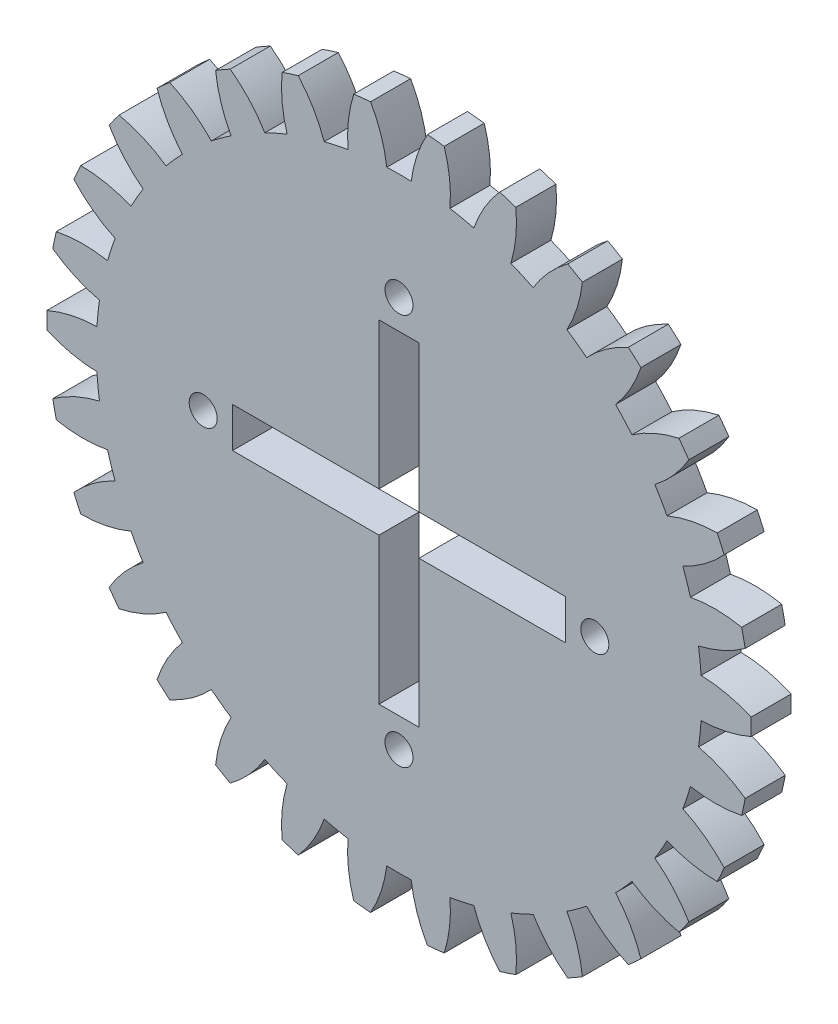
from build123d import *

# Parameters (mm, degrees)
EXTRUDE_1_DEPTH     = 5
CUT_EXTRUDE_2_DEPTH = 10
SKETCH_4_R          = 1.75
CUT_EXTRUDE_3_DEPTH = 10


with BuildPart() as part:
    # 草图1 → 凸台-拉伸1 (new body)
    with BuildSketch(Plane.XY):
        with BuildLine():
            ThreePointArc((-43.98730465, -1.056896208), (-40.927651292, -2.051995365), (-37.733051967, -2.434403732))
            ThreePointArc((-37.733051967, -2.434403732), (-37.604364647, -3.952377989), (-37.414635246, -5.463936465))
            ThreePointArc((-37.414635246, -5.463936465), (-40.459917741, -6.502182838), (-43.245817584, -8.111674394))
            ThreePointArc((-43.245817584, -8.111674394), (-43.038494432, -9.148114396), (-42.806335429, -10.179275375))
            ThreePointArc((-42.806335429, -10.179275375), (-39.606650089, -10.516491524), (-36.402353254, -10.226348803))
            ThreePointArc((-36.402353254, -10.226348803), (-35.960873466, -11.684396083), (-35.461019429, -13.123476419))
            ThreePointArc((-35.461019429, -13.123476419), (-38.223891636, -14.772184451), (-40.614280773, -16.925725901))
            ThreePointArc((-40.614280773, -16.925725901), (-40.196000136, -17.896412295), (-39.754523941, -18.856771362))
            ThreePointArc((-39.754523941, -18.856771362), (-36.554648223, -18.52136654), (-33.480697026, -17.571353361))
            ThreePointArc((-33.480697026, -17.571353361), (-32.745719555, -18.90575), (-31.957586902, -20.20945748))
            ThreePointArc((-31.957586902, -20.20945748), (-34.317298048, -22.396570718), (-36.207705003, -25.000041968))
            ThreePointArc((-36.207705003, -25.000041968), (-35.596747752, -25.862551101), (-34.965248994, -26.710135956))
            ThreePointArc((-34.965248994, -26.710135956), (-31.905032822, -25.716768963), (-29.095773679, -24.14840546))
            ThreePointArc((-29.095773679, -24.14840546), (-28.099420569, -25.300831922), (-27.057454478, -26.412188274))
            ThreePointArc((-27.057454478, -26.412188274), (-28.910873863, -29.042119374), (-30.218678781, -31.981736237))
            ThreePointArc((-30.218678781, -31.981736237), (-29.44174668, -32.698372321), (-28.647824884, -33.396139438))
            ThreePointArc((-28.647824884, -33.396139438), (-25.861014388, -31.788225179), (-23.439225406, -29.670056364))
            ThreePointArc((-23.439225406, -29.670056364), (-22.225042067, -30.590146083), (-20.974781458, -31.4605797))
            ThreePointArc((-20.974781458, -31.4605797), (-22.24090576, -34.418388053), (-22.908951291, -37.565675167))
            ThreePointArc((-22.908951291, -37.565675167), (-22, -38.105117767), (-21.07835336, -38.622571375))
            ThreePointArc((-21.07835336, -38.622571375), (-18.686745531, -36.470383418), (-16.758270509, -33.894983431))
            ThreePointArc((-16.758270509, -33.894983431), (-15.37932258, -34.542524072), (-13.97540984, -35.133992828))
            ThreePointArc((-13.97540984, -35.133992828), (-14.598903352, -38.290408018), (-14.5979927, -41.507813832))
            ThreePointArc((-14.5979927, -41.507813832), (-13.596747752, -41.846486717), (-12.587656648, -42.161011612))
            ThreePointArc((-12.587656648, -42.161011612), (-10.695776226, -39.558610898), (-9.344898775, -36.638537077))
            ThreePointArc((-9.344898775, -36.638537077), (-7.861452897, -36.985228005), (-6.36524575, -37.271881879))
            ThreePointArc((-6.36524575, -37.271881879), (-6.318858814, -40.488953413), (-5.649031779, -43.635861857))
            ThreePointArc((-5.649031779, -43.635861857), (-4.599252384, -43.758963396), (-3.546818938, -43.85681333))
            ThreePointArc((-3.546818938, -43.85681333), (-2.237350175, -40.917937258), (-1.523110123, -37.780810841))
            ThreePointArc((-1.523110123, -37.780810841), (0, -37.8115), (1.523110123, -37.780810841))
            ThreePointArc((1.523110123, -37.780810841), (2.237350175, -40.917937258), (3.546818938, -43.85681333))
            ThreePointArc((3.546818938, -43.85681333), (4.599252384, -43.758963396), (5.649031779, -43.635861857))
            ThreePointArc((5.649031779, -43.635861857), (6.318858814, -40.488953413), (6.36524575, -37.271881879))
            ThreePointArc((6.36524575, -37.271881879), (7.861452897, -36.985228005), (9.344898775, -36.638537077))
            ThreePointArc((9.344898775, -36.638537077), (10.695776226, -39.558610898), (12.587656648, -42.161011612))
            ThreePointArc((12.587656648, -42.161011612), (13.596747752, -41.846486717), (14.5979927, -41.507813832))
            ThreePointArc((14.5979927, -41.507813832), (14.598903352, -38.290408018), (13.97540984, -35.133992828))
            ThreePointArc((13.97540984, -35.133992828), (15.37932258, -34.542524072), (16.758270509, -33.894983431))
            ThreePointArc((16.758270509, -33.894983431), (18.686745531, -36.470383418), (21.07835336, -38.622571375))
            ThreePointArc((21.07835336, -38.622571375), (22, -38.105117767), (22.908951291, -37.565675167))
            ThreePointArc((22.908951291, -37.565675167), (22.24090576, -34.418388053), (20.974781458, -31.4605797))
            ThreePointArc((20.974781458, -31.4605797), (22.225042067, -30.590146083), (23.439225406, -29.670056364))
            ThreePointArc((23.439225406, -29.670056364), (25.861014388, -31.788225179), (28.647824884, -33.396139438))
            ThreePointArc((28.647824884, -33.396139438), (29.44174668, -32.698372321), (30.218678781, -31.981736237))
            ThreePointArc((30.218678781, -31.981736237), (28.910873863, -29.042119374), (27.057454478, -26.412188274))
            ThreePointArc((27.057454478, -26.412188274), (28.099420569, -25.300831922), (29.095773679, -24.14840546))
            ThreePointArc((29.095773679, -24.14840546), (31.905032822, -25.716768963), (34.965248994, -26.710135956))
            ThreePointArc((34.965248994, -26.710135956), (35.596747752, -25.862551101), (36.207705003, -25.000041968))
            ThreePointArc((36.207705003, -25.000041968), (34.317298048, -22.396570718), (31.957586902, -20.20945748))
            ThreePointArc((31.957586902, -20.20945748), (32.745719555, -18.90575), (33.480697026, -17.571353361))
            ThreePointArc((33.480697026, -17.571353361), (36.554648223, -18.52136654), (39.754523941, -18.856771362))
            ThreePointArc((39.754523941, -18.856771362), (40.196000136, -17.896412295), (40.614280773, -16.925725901))
            ThreePointArc((40.614280773, -16.925725901), (38.223891636, -14.772184451), (35.461019429, -13.123476419))
            ThreePointArc((35.461019429, -13.123476419), (35.960873466, -11.684396083), (36.402353254, -10.226348803))
            ThreePointArc((36.402353254, -10.226348803), (39.606650089, -10.516491524), (42.806335429, -10.179275375))
            ThreePointArc((42.806335429, -10.179275375), (43.038494432, -9.148114396), (43.245817584, -8.111674394))
            ThreePointArc((43.245817584, -8.111674394), (40.459917741, -6.502182838), (37.414635246, -5.463936465))
            ThreePointArc((37.414635246, -5.463936465), (37.604364647, -3.952377989), (37.733051967, -2.434403732))
            ThreePointArc((37.733051967, -2.434403732), (40.927651292, -2.051995365), (43.98730465, -1.056896208))
            ThreePointArc((43.98730465, -1.056896208), (44, 0), (43.98730465, 1.056896208))
            ThreePointArc((43.98730465, 1.056896208), (40.927651292, 2.051995365), (37.733051967, 2.434403732))
            ThreePointArc((37.733051967, 2.434403732), (37.604364647, 3.952377989), (37.414635246, 5.463936465))
            ThreePointArc((37.414635246, 5.463936465), (40.459917741, 6.502182838), (43.245817584, 8.111674394))
            ThreePointArc((43.245817584, 8.111674394), (43.038494432, 9.148114396), (42.806335429, 10.179275375))
            ThreePointArc((42.806335429, 10.179275375), (39.606650089, 10.516491524), (36.402353254, 10.226348803))
            ThreePointArc((36.402353254, 10.226348803), (35.960873466, 11.684396083), (35.461019429, 13.123476419))
            ThreePointArc((35.461019429, 13.123476419), (38.223891636, 14.772184451), (40.614280773, 16.925725901))
            ThreePointArc((40.614280773, 16.925725901), (40.196000136, 17.896412295), (39.754523941, 18.856771362))
            ThreePointArc((39.754523941, 18.856771362), (36.554648223, 18.52136654), (33.480697026, 17.571353361))
            ThreePointArc((33.480697026, 17.571353361), (32.745719555, 18.90575), (31.957586902, 20.20945748))
            ThreePointArc((31.957586902, 20.20945748), (34.317298048, 22.396570718), (36.207705003, 25.000041968))
            ThreePointArc((36.207705003, 25.000041968), (35.596747752, 25.862551101), (34.965248994, 26.710135956))
            ThreePointArc((34.965248994, 26.710135956), (31.905032822, 25.716768963), (29.095773679, 24.14840546))
            ThreePointArc((29.095773679, 24.14840546), (28.099420569, 25.300831922), (27.057454478, 26.412188274))
            ThreePointArc((27.057454478, 26.412188274), (28.910873863, 29.042119374), (30.218678781, 31.981736237))
            ThreePointArc((30.218678781, 31.981736237), (29.44174668, 32.698372321), (28.647824884, 33.396139438))
            ThreePointArc((28.647824884, 33.396139438), (25.861014388, 31.788225179), (23.439225406, 29.670056364))
            ThreePointArc((23.439225406, 29.670056364), (22.225042067, 30.590146083), (20.974781458, 31.4605797))
            ThreePointArc((20.974781458, 31.4605797), (22.24090576, 34.418388053), (22.908951291, 37.565675167))
            ThreePointArc((22.908951291, 37.565675167), (22, 38.105117767), (21.07835336, 38.622571375))
            ThreePointArc((21.07835336, 38.622571375), (18.686745531, 36.470383418), (16.758270509, 33.894983431))
            ThreePointArc((16.758270509, 33.894983431), (15.37932258, 34.542524072), (13.97540984, 35.133992828))
            ThreePointArc((13.97540984, 35.133992828), (14.598903352, 38.290408018), (14.5979927, 41.507813832))
            ThreePointArc((14.5979927, 41.507813832), (13.596747752, 41.846486717), (12.587656648, 42.161011612))
            ThreePointArc((12.587656648, 42.161011612), (10.695776226, 39.558610898), (9.344898775, 36.638537077))
            ThreePointArc((9.344898775, 36.638537077), (7.861452897, 36.985228005), (6.36524575, 37.271881879))
            ThreePointArc((6.36524575, 37.271881879), (6.318858814, 40.488953413), (5.649031779, 43.635861857))
            ThreePointArc((5.649031779, 43.635861857), (4.599252384, 43.758963396), (3.546818938, 43.85681333))
            ThreePointArc((3.546818938, 43.85681333), (2.237350175, 40.917937258), (1.523110123, 37.780810841))
            ThreePointArc((1.523110123, 37.780810841), (0, 37.8115), (-1.523110123, 37.780810841))
            ThreePointArc((-1.523110123, 37.780810841), (-2.237350175, 40.917937258), (-3.546818938, 43.85681333))
            ThreePointArc((-3.546818938, 43.85681333), (-4.599252384, 43.758963396), (-5.649031779, 43.635861857))
            ThreePointArc((-5.649031779, 43.635861857), (-6.318858814, 40.488953413), (-6.36524575, 37.271881879))
            ThreePointArc((-6.36524575, 37.271881879), (-7.861452897, 36.985228005), (-9.344898775, 36.638537077))
            ThreePointArc((-9.344898775, 36.638537077), (-10.695776226, 39.558610898), (-12.587656648, 42.161011612))
            ThreePointArc((-12.587656648, 42.161011612), (-13.596747752, 41.846486717), (-14.5979927, 41.507813832))
            ThreePointArc((-14.5979927, 41.507813832), (-14.598903352, 38.290408018), (-13.97540984, 35.133992828))
            ThreePointArc((-13.97540984, 35.133992828), (-15.37932258, 34.542524072), (-16.758270509, 33.894983431))
            ThreePointArc((-16.758270509, 33.894983431), (-18.686745531, 36.470383418), (-21.07835336, 38.622571375))
            ThreePointArc((-21.07835336, 38.622571375), (-22, 38.105117767), (-22.908951291, 37.565675167))
            ThreePointArc((-22.908951291, 37.565675167), (-22.24090576, 34.418388053), (-20.974781458, 31.4605797))
            ThreePointArc((-20.974781458, 31.4605797), (-22.225042067, 30.590146083), (-23.439225406, 29.670056364))
            ThreePointArc((-23.439225406, 29.670056364), (-25.861014388, 31.788225179), (-28.647824884, 33.396139438))
            ThreePointArc((-28.647824884, 33.396139438), (-29.44174668, 32.698372321), (-30.218678781, 31.981736237))
            ThreePointArc((-30.218678781, 31.981736237), (-28.910873863, 29.042119374), (-27.057454478, 26.412188274))
            ThreePointArc((-27.057454478, 26.412188274), (-28.099420569, 25.300831922), (-29.095773679, 24.14840546))
            ThreePointArc((-29.095773679, 24.14840546), (-31.905032822, 25.716768963), (-34.965248994, 26.710135956))
            ThreePointArc((-34.965248994, 26.710135956), (-35.596747752, 25.862551101), (-36.207705003, 25.000041968))
            ThreePointArc((-36.207705003, 25.000041968), (-34.317298048, 22.396570718), (-31.957586902, 20.20945748))
            ThreePointArc((-31.957586902, 20.20945748), (-32.745719555, 18.90575), (-33.480697026, 17.571353361))
            ThreePointArc((-33.480697026, 17.571353361), (-36.554648223, 18.52136654), (-39.754523941, 18.856771362))
            ThreePointArc((-39.754523941, 18.856771362), (-40.196000136, 17.896412295), (-40.614280773, 16.925725901))
            ThreePointArc((-40.614280773, 16.925725901), (-38.223891636, 14.772184451), (-35.461019429, 13.123476419))
            ThreePointArc((-35.461019429, 13.123476419), (-35.960873466, 11.684396083), (-36.402353254, 10.226348803))
            ThreePointArc((-36.402353254, 10.226348803), (-39.606650089, 10.516491524), (-42.806335429, 10.179275375))
            ThreePointArc((-42.806335429, 10.179275375), (-43.038494432, 9.148114396), (-43.245817584, 8.111674394))
            ThreePointArc((-43.245817584, 8.111674394), (-40.459917741, 6.502182838), (-37.414635246, 5.463936465))
            ThreePointArc((-37.414635246, 5.463936465), (-37.604364647, 3.952377989), (-37.733051967, 2.434403732))
            ThreePointArc((-37.733051967, 2.434403732), (-40.927651292, 2.051995365), (-43.98730465, 1.056896208))
            ThreePointArc((-43.98730465, 1.056896208), (-44, 0), (-43.98730465, -1.056896208))
        make_face()
    extrude(amount=EXTRUDE_1_DEPTH)

    # 草图3 → 切除-拉伸2 (cut)
    with BuildSketch(Plane.XY.offset(5)):
        Polygon((2.5, 2.5), (2.5, 20.79), (-2.5, 20.79), (-2.5, 2.5), (-20.79, 2.5), (-20.79, -2.5), (-2.5, -2.5), (-2.5, -20.79), (2.5, -20.79), (2.5, -2.5), (20.79, -2.5), (20.79, 2.5), align=None)
    extrude(amount=-CUT_EXTRUDE_2_DEPTH, mode=Mode.SUBTRACT)

    # 草图4 → 切除-拉伸3 (cut)
    with BuildSketch(Plane.XY.offset(5)):
        with Locations((0, 24.46)):
            Circle(SKETCH_4_R)
        with Locations((24.46, 0)):
            Circle(SKETCH_4_R)
        with Locations((0, -24.46)):
            Circle(SKETCH_4_R)
        with Locations((-24.46, 0)):
            Circle(SKETCH_4_R)
    extrude(amount=-CUT_EXTRUDE_3_DEPTH, mode=Mode.SUBTRACT)


solid = part.part
